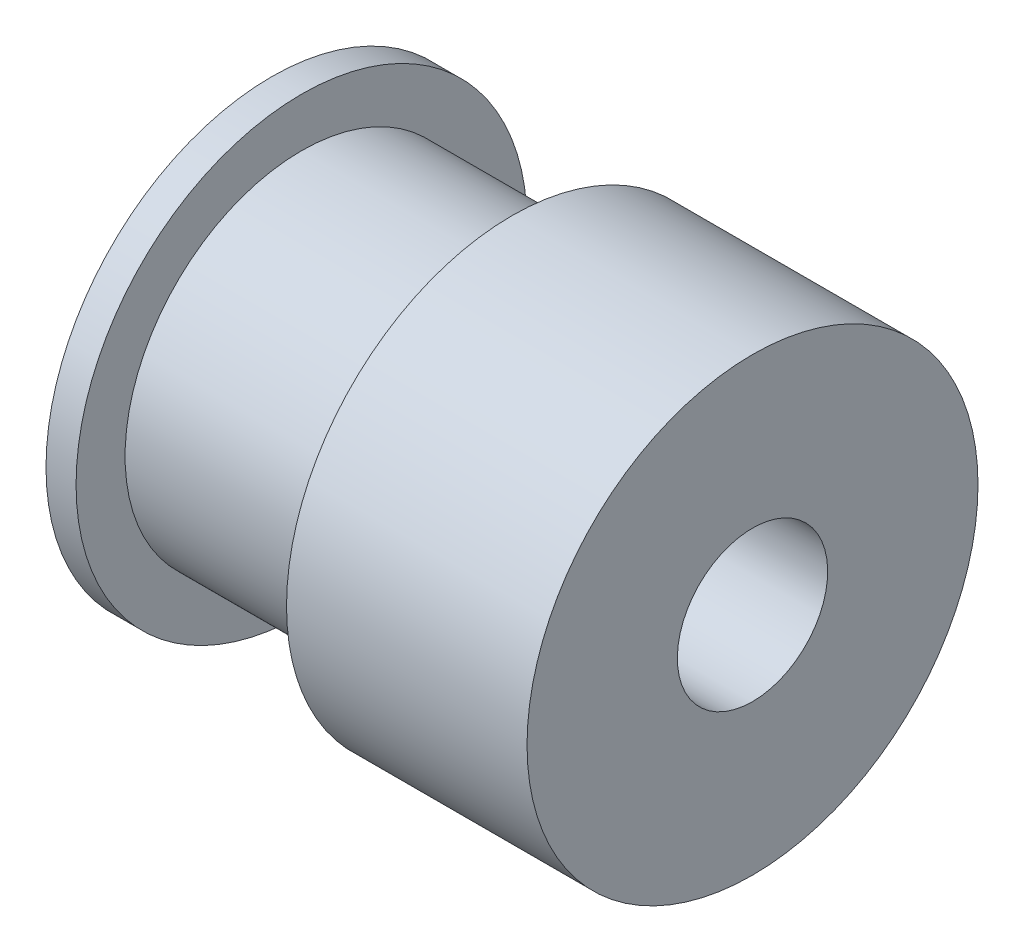
from build123d import *

# Parameters (mm, degrees)
SKETCH1_W               = 7
SKETCH1_H               = 7.5
SKETCH2_R               = 2.5
CUT_EXTRUDE1_DEPTH      = 1
CUT_EXTRUDE1_DEPTH_BACK = 17


with BuildPart() as part:
    # Sketch1 → Revolve1 (revolve)
    with BuildSketch(Plane.XY):
        Polygon((-7, 7.5), (-7, 0), (-16, 0), (-16, 7.5), (-15, 7.5), (-15, 5.87), (-8, 5.87), (-8, 7.5), align=None)
        with Locations((-3.5, 3.75)):
            Rectangle(SKETCH1_W, SKETCH1_H)
    revolve(axis=Axis((-7, 0, 0), (-1, 0, 0)))

    # Sketch2 → Cut-Extrude1 (cut, two sides)
    with BuildSketch(Plane.ZY.offset(16)) as cut_extrude1_sk:
        Circle(SKETCH2_R)
    extrude(amount=CUT_EXTRUDE1_DEPTH, mode=Mode.SUBTRACT)
    extrude(cut_extrude1_sk.sketch, amount=-CUT_EXTRUDE1_DEPTH_BACK, mode=Mode.SUBTRACT)


solid = part.part
